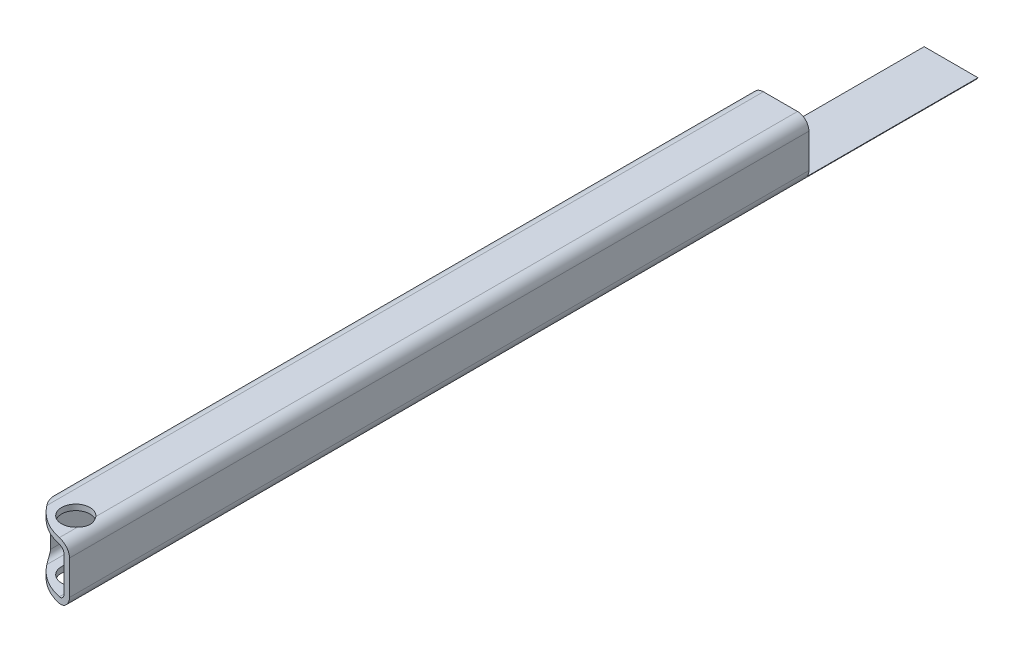
from build123d import *

# Parameters (mm, degrees)
BOSS_EXTRUDE1_DEPTH = 203.2
SKETCH2_R           = 3.175
CUT_EXTRUDE1_DEPTH  = 13.7
SKETCH3_W           = 38.1
SKETCH3_H           = 11.43
CUT_EXTRUDE2_DEPTH  = 13.7000001
CUT_EXTRUDE3_DEPTH  = 13.7000001


with BuildPart() as part:
    # Sketch1 → Boss-Extrude1 (new body)
    with BuildSketch(Plane.XY):
        with BuildLine():
            Line((2.54, 0), (10.16, 0))
            ThreePointArc((10.16, 0), (11.956051224, 0.743948776), (12.7, 2.54))
            Line((12.7, 2.54), (12.7, 10.16))
            ThreePointArc((12.7, 10.16), (11.956051224, 11.956051224), (10.16, 12.7))
            Line((10.16, 12.7), (2.54, 12.7))
            ThreePointArc((2.54, 12.7), (0.743948776, 11.956051224), (0, 10.16))
            Line((0, 10.16), (0, 2.54))
            ThreePointArc((0, 2.54), (0.743948776, 0.743948776), (2.54, 0))
        make_face()
        with BuildLine():
            Line((2.54, 1.27), (10.16, 1.27))
            ThreePointArc((10.16, 1.27), (11.058025612, 1.641974388), (11.43, 2.54))
            Line((11.43, 2.54), (11.43, 10.16))
            ThreePointArc((11.43, 10.16), (11.058025612, 11.058025612), (10.16, 11.43))
            Line((10.16, 11.43), (2.54, 11.43))
            ThreePointArc((2.54, 11.43), (1.641974388, 11.058025612), (1.27, 10.16))
            Line((1.27, 10.16), (1.27, 2.54))
            ThreePointArc((1.27, 2.54), (1.641974388, 1.641974388), (2.54, 1.27))
        make_face(mode=Mode.SUBTRACT)
    extrude(amount=BOSS_EXTRUDE1_DEPTH)

    # Sketch2 → Cut-Extrude1 (cut, through all)
    with BuildSketch(Plane(origin=(0, 12.7, 0), x_dir=(1, 0, 0), z_dir=(0, 1, 0))):
        with Locations((7.747, -196.85)):
            Circle(SKETCH2_R)
    extrude(amount=-CUT_EXTRUDE1_DEPTH, mode=Mode.SUBTRACT)

    # Sketch3 → Cut-Extrude2 (cut, through all)
    with BuildSketch(Plane.ZY):
        with Locations((19.05, 6.985)):
            Rectangle(SKETCH3_W, SKETCH3_H)
    extrude(amount=-CUT_EXTRUDE2_DEPTH, mode=Mode.SUBTRACT)

    # Sketch4 → Cut-Extrude3 (cut, through all)
    with BuildSketch(Plane(origin=(0, 12.7, 0), x_dir=(1, 0, 0), z_dir=(0, 1, 0))):
        with BuildLine():
            Line((0, -203.2), (12.7, -203.2))
            ThreePointArc((12.7, -203.2), (3.719743879, -199.480256121), (0, -190.5))
            Line((0, -190.5), (0, -203.2))
        make_face()
    extrude(amount=-CUT_EXTRUDE3_DEPTH, mode=Mode.SUBTRACT)


solid = part.part
